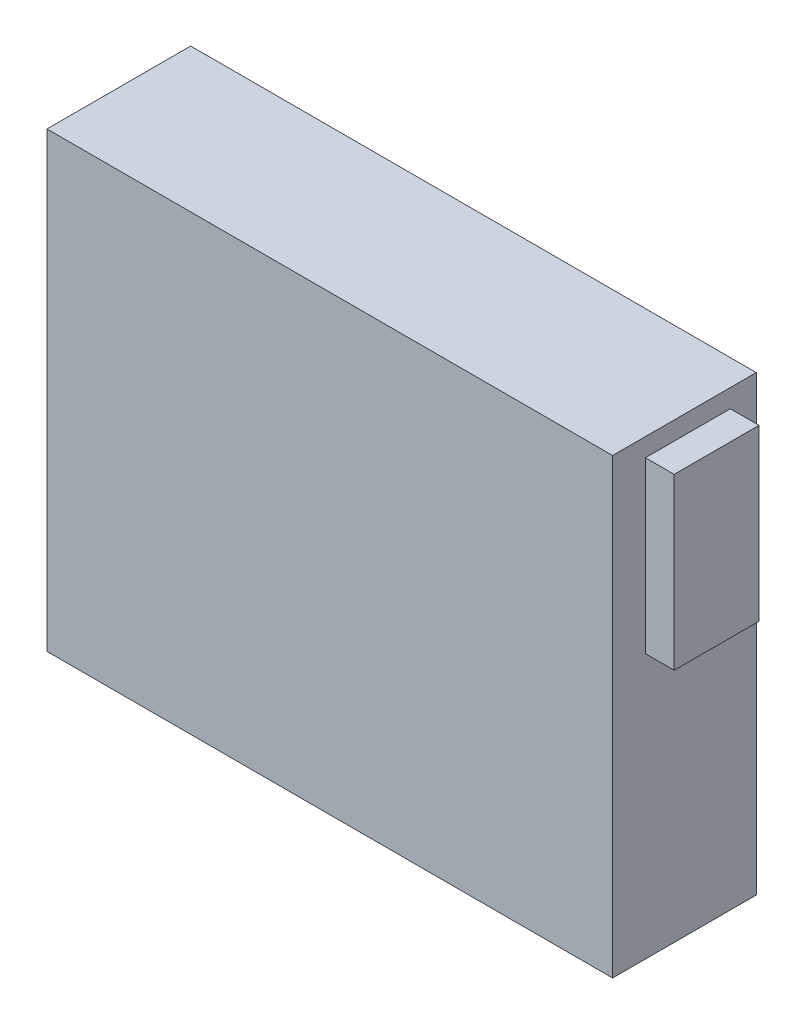
from build123d import *

# Parameters (mm, degrees)
SKETCH2_W           = 100
SKETCH2_H           = 80
BOSS_EXTRUDE2_DEPTH = 25.4
SKETCH3_W           = 15
SKETCH3_H           = 30
CUT_EXTRUDE1_DEPTH  = 10.922
SKETCH4_W           = 15
SKETCH4_H           = 30
CUT_EXTRUDE2_DEPTH  = 10.922
SKETCH3_2_W         = 15
SKETCH3_2_H         = 30
BOSS_EXTRUDE3_DEPTH = 5.08
SKETCH4_2_W         = 15
SKETCH4_2_H         = 30
BOSS_EXTRUDE4_DEPTH = 5.08


with BuildPart() as part:
    # Sketch2 → Boss-Extrude2 (new body)
    with BuildSketch(Plane.XY):
        with Locations((50, 40)):
            Rectangle(SKETCH2_W, SKETCH2_H)
    extrude(amount=BOSS_EXTRUDE2_DEPTH)

    # Sketch3 → Cut-Extrude1 (cut)
    with BuildSketch(Plane(origin=(100, 0, 0), x_dir=(0, 0, -1), z_dir=(1, 0, 0))):
        with Locations((-12.093564274, 61.755363105)):
            Rectangle(SKETCH3_W, SKETCH3_H)
    extrude(amount=-CUT_EXTRUDE1_DEPTH, mode=Mode.SUBTRACT)

    # Sketch4 → Cut-Extrude2 (cut)
    with BuildSketch(Plane.ZY):
        with Locations((12.729363154, 15.183095109)):
            Rectangle(SKETCH4_W, SKETCH4_H)
    extrude(amount=-CUT_EXTRUDE2_DEPTH, mode=Mode.SUBTRACT)


with BuildPart() as body_2:
    # Sketch3_2 → Boss-Extrude3 (new body)
    with BuildSketch(Plane(origin=(100, 0, 0), x_dir=(0, 0, -1), z_dir=(1, 0, 0))):
        with Locations((-12.093564274, 61.755363105)):
            Rectangle(SKETCH3_2_W, SKETCH3_2_H)
    extrude(amount=BOSS_EXTRUDE3_DEPTH)


with BuildPart() as body_3:
    # Sketch4_2 → Boss-Extrude4 (new body)
    with BuildSketch(Plane.ZY):
        with Locations((12.729363154, 15.183095109)):
            Rectangle(SKETCH4_2_W, SKETCH4_2_H)
    extrude(amount=BOSS_EXTRUDE4_DEPTH)


solid = Compound([part.part, body_2.part, body_3.part])
